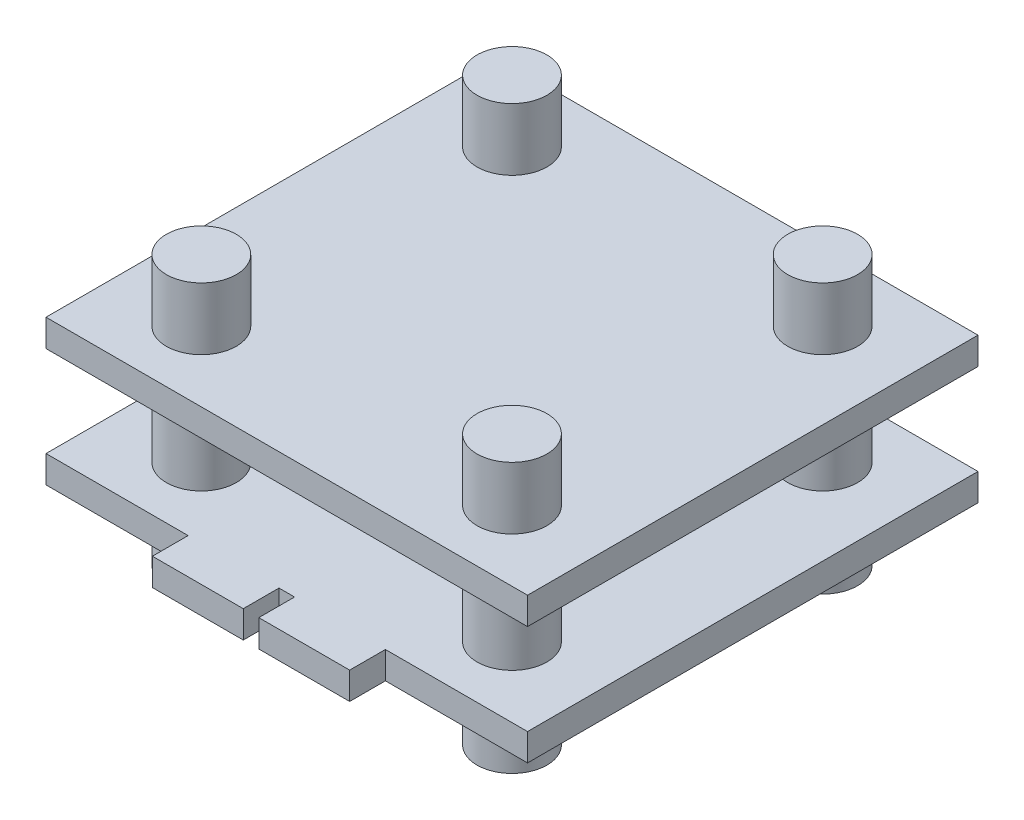
from build123d import *

# Parameters (mm, degrees)
SKETCH1_W           = 31
SKETCH1_H           = 29
BOSS_EXTRUDE1_DEPTH = 1.75
SKETCH2_R           = 2.25
BOSS_EXTRUDE2_DEPTH = 5.85
SKETCH3_W           = 31
SKETCH3_H           = 29
BOSS_EXTRUDE3_DEPTH = 1.75
SKETCH4_R           = 2.25
BOSS_EXTRUDE4_DEPTH = 4
SKETCH5_R           = 2.25
BOSS_EXTRUDE5_DEPTH = 4
SKETCH6_W           = 5.85
SKETCH6_H           = 2.3
BOSS_EXTRUDE6_DEPTH = 1.75


with BuildPart() as part:
    # Sketch1 → Boss-Extrude1 (new body)
    with BuildSketch(Plane(origin=(0, 0, 0), x_dir=(1, 0, 0), z_dir=(0, 1, 0))):
        Rectangle(SKETCH1_W, SKETCH1_H)
    extrude(amount=BOSS_EXTRUDE1_DEPTH)

    # Sketch2 → Boss-Extrude2 (add)
    with BuildSketch(Plane(origin=(0, 1.75, 0), x_dir=(1, 0, 0), z_dir=(0, 1, 0))):
        with Locations((-10, 10)):
            Circle(SKETCH2_R)
        with Locations((10, 10)):
            Circle(SKETCH2_R)
        with Locations((10, -10)):
            Circle(SKETCH2_R)
        with Locations((-10, -10)):
            Circle(SKETCH2_R)
    extrude(amount=BOSS_EXTRUDE2_DEPTH)

    # Sketch3 → Boss-Extrude3 (add)
    with BuildSketch(Plane(origin=(0, 7.6, 0), x_dir=(1, 0, 0), z_dir=(0, 1, 0))):
        Rectangle(SKETCH3_W, SKETCH3_H)
    extrude(amount=BOSS_EXTRUDE3_DEPTH)

    # Sketch4 → Boss-Extrude4 (add)
    with BuildSketch(Plane(origin=(0, 9.35, 0), x_dir=(1, 0, 0), z_dir=(0, 1, 0))):
        with Locations((-10, 10)):
            Circle(SKETCH4_R)
        with Locations((10, 10)):
            Circle(SKETCH4_R)
        with Locations((10, -10)):
            Circle(SKETCH4_R)
        with Locations((-10, -10)):
            Circle(SKETCH4_R)
    extrude(amount=BOSS_EXTRUDE4_DEPTH)

    # Sketch5 → Boss-Extrude5 (add)
    with BuildSketch(Plane.XZ):
        with Locations((10, 10)):
            Circle(SKETCH5_R)
        with Locations((10, -10)):
            Circle(SKETCH5_R)
        with Locations((-10, -10)):
            Circle(SKETCH5_R)
        with Locations((-10, 10)):
            Circle(SKETCH5_R)
    extrude(amount=BOSS_EXTRUDE5_DEPTH)

    # Sketch6 → Boss-Extrude6 (add)
    with BuildSketch(Plane.XZ):
        with Locations((3.425, 15.65)):
            Rectangle(SKETCH6_W, SKETCH6_H)
        with Locations((-3.425, 15.65)):
            Rectangle(SKETCH6_W, SKETCH6_H)
    extrude(amount=-BOSS_EXTRUDE6_DEPTH)


solid = part.part
